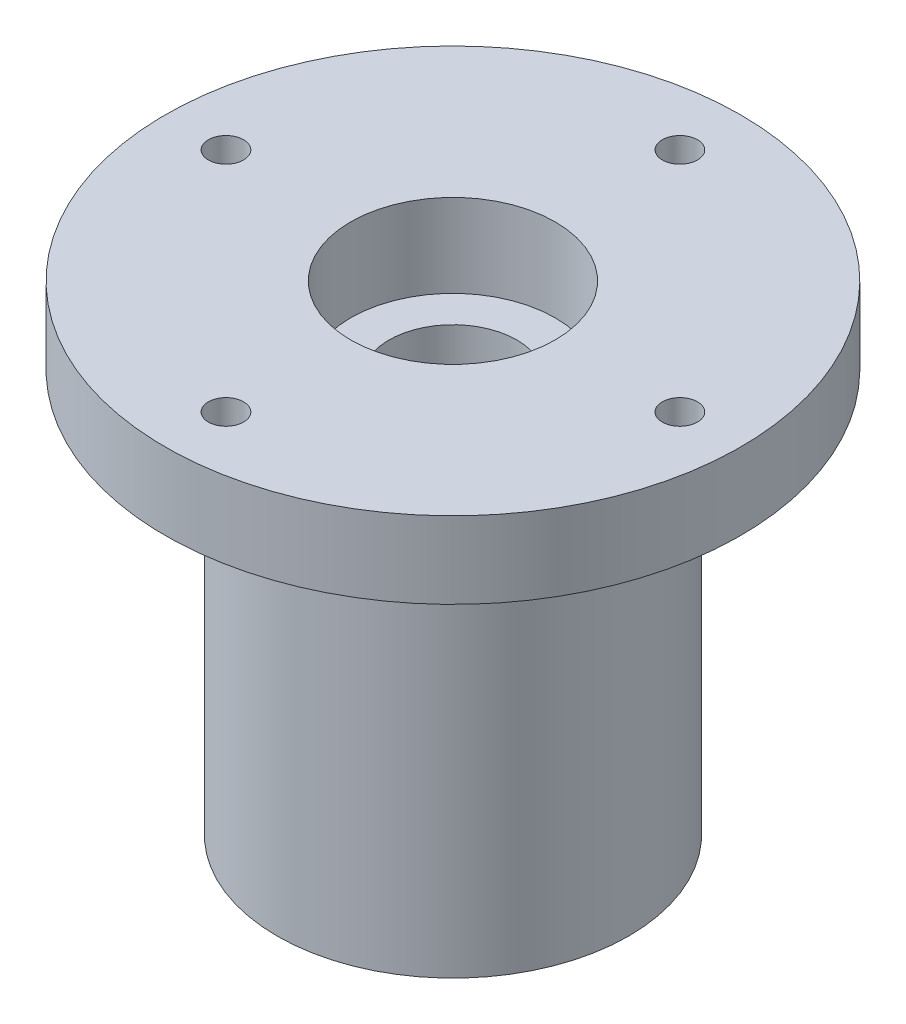
from build123d import *

# Parameters (mm, degrees)
M5_CLEARANCE_HOLE1_D           = 5.5
M5_CLEARANCE_HOLE1_CSINK_D     = 12
M5_CLEARANCE_HOLE1_CSINK_ANGLE = 90


with BuildPart() as part:
    # Sketch1 → Revolve1 (revolve)
    with BuildSketch(Plane.XY):
        Polygon((-45, 0), (-16, 0), (-16, -13), (-10, -13), (-10, -62), (-16, -62), (-16, -75), (-27.5, -75), (-27.5, -12), (-45, -12), align=None)
    revolve(axis=Axis((0, 0, 0), (0, 1, 0)))

    # M5 Clearance Hole1 (through all)
    with Locations(Plane(origin=(0, -12, 0), x_dir=(-1, 0, 0), z_dir=(0, -1, 0))):
        with Locations((-35.5, 0), (0, -35.5), (35.5, 0), (0, 35.5)):
            CounterSinkHole(M5_CLEARANCE_HOLE1_D / 2, M5_CLEARANCE_HOLE1_CSINK_D / 2, counter_sink_angle=M5_CLEARANCE_HOLE1_CSINK_ANGLE)


solid = part.part
